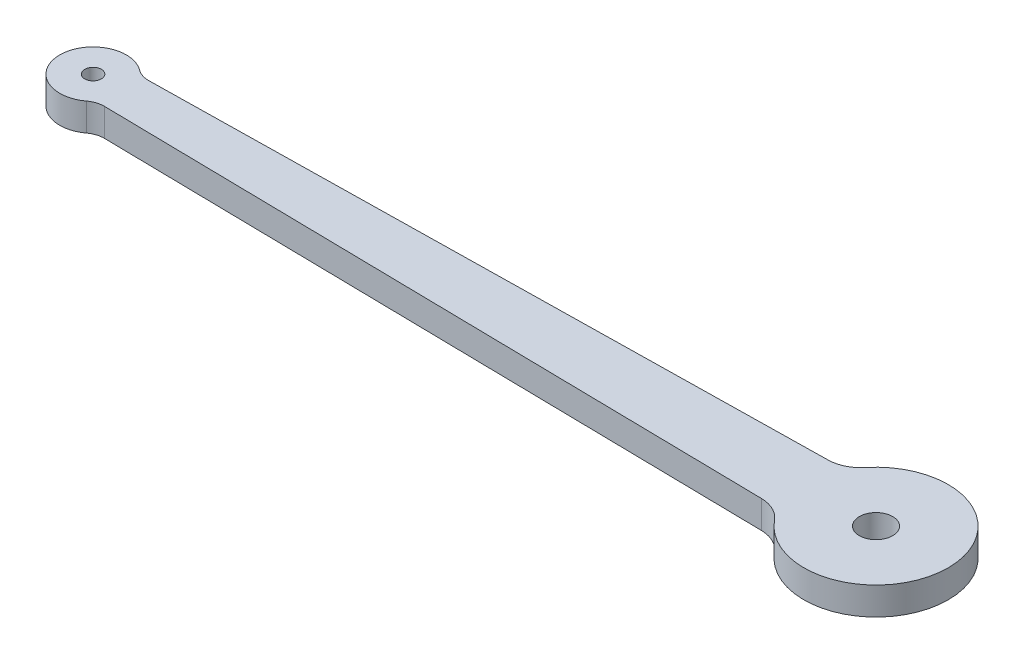
from build123d import *

# Parameters (mm, degrees)
BOSS_EXTRUDE1_DEPTH = 2.5
CUT_EXTRUDE1_REACH  = 4.5
SKETCH2_R           = 0.75
SKETCH2_R_2         = 1.5


with BuildPart() as part:
    # Sketch1 → Boss-Extrude1 (new body)
    with BuildSketch(Plane(origin=(0, 0, 0), x_dir=(1, 0, 0), z_dir=(0, 1, 0))):
        with BuildLine():
            Line((-32.216386231, 2), (27.934070474, 3))
            ThreePointArc((27.934070474, 3), (29.194347957, 3.300786008), (30.210243769, 4.104979553))
            ThreePointArc((30.210243769, 4.104979553), (41.75, 0), (30.210243769, -4.104979553))
            ThreePointArc((30.210243769, -4.104979553), (29.194347957, -3.300786008), (27.934070474, -3))
            Line((27.934070474, -3), (-32.216386231, -2))
            ThreePointArc((-32.216386231, -2), (-32.86638269, -2.097194277), (-33.449778955, -2.3998342))
            ThreePointArc((-33.449778955, -2.3998342), (-38.25, 0), (-33.449778955, 2.3998342))
            ThreePointArc((-33.449778955, 2.3998342), (-32.86638269, 2.097194277), (-32.216386231, 2))
        make_face()
    extrude(amount=BOSS_EXTRUDE1_DEPTH)

    # Sketch2 → Cut-Extrude1 (cut, up to next)
    with BuildSketch(Plane(origin=(0, 2.5, 0), x_dir=(1, 0, 0), z_dir=(0, 1, 0)), mode=Mode.PRIVATE) as cut_extrude1_sk1:
        with Locations((-35.25, 0)):
            Circle(SKETCH2_R)
    cut_extrude1_tool1 = extrude(cut_extrude1_sk1.sketch, amount=-CUT_EXTRUDE1_REACH, mode=Mode.PRIVATE) & part.part
    add(cut_extrude1_tool1.solids().sort_by_distance((-35.25, 2.5, 0))[0], mode=Mode.SUBTRACT)
    # Sketch2 → Cut-Extrude1 (cut, up to next)
    with BuildSketch(Plane(origin=(0, 2.5, 0), x_dir=(1, 0, 0), z_dir=(0, 1, 0)), mode=Mode.PRIVATE) as cut_extrude1_sk2:
        with Locations((35.25, 0)):
            Circle(SKETCH2_R_2)
    cut_extrude1_tool2 = extrude(cut_extrude1_sk2.sketch, amount=-CUT_EXTRUDE1_REACH, mode=Mode.PRIVATE) & part.part
    add(cut_extrude1_tool2.solids().sort_by_distance((35.25, 2.5, 0))[0], mode=Mode.SUBTRACT)


solid = part.part
